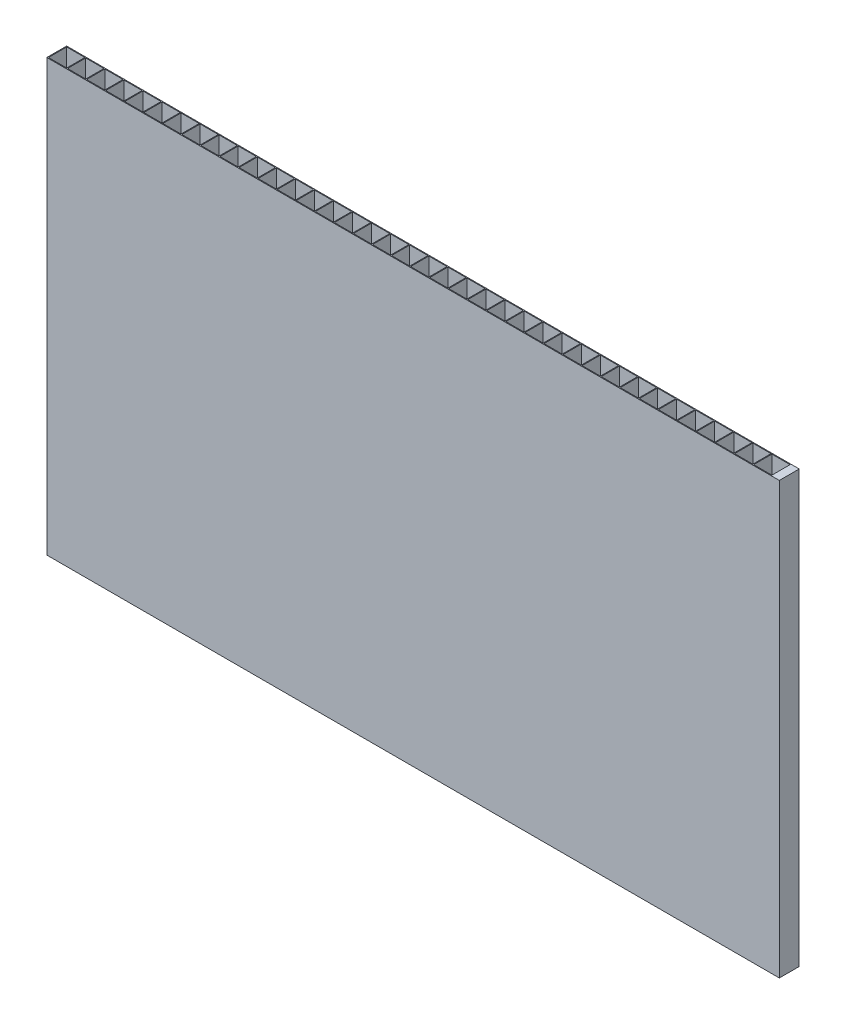
from build123d import *

# Parameters (mm, degrees)
SKETCH1_W           = 221
SKETCH1_H           = 6
SKETCH1_W_2         = 5.5
SKETCH1_H_2         = 5.5
BOSS_EXTRUDE1_DEPTH = 130


with BuildPart() as part:
    # Sketch1 → Boss-Extrude1 (new body)
    with BuildSketch(Plane(origin=(0, 0, 0), x_dir=(1, 0, 0), z_dir=(0, 1, 0))):
        with Locations((110.5, 3)):
            Rectangle(SKETCH1_W, SKETCH1_H)
        with Locations((8.75, 3)):
            Rectangle(SKETCH1_W_2, SKETCH1_H_2, mode=Mode.SUBTRACT)
        with Locations((3, 3)):
            Rectangle(SKETCH1_W_2, SKETCH1_H_2, mode=Mode.SUBTRACT)
        with Locations((14.5, 3)):
            Rectangle(SKETCH1_W_2, SKETCH1_H_2, mode=Mode.SUBTRACT)
        with Locations((20.25, 3)):
            Rectangle(SKETCH1_W_2, SKETCH1_H_2, mode=Mode.SUBTRACT)
        with Locations((26, 3)):
            Rectangle(SKETCH1_W_2, SKETCH1_H_2, mode=Mode.SUBTRACT)
        with Locations((31.75, 3)):
            Rectangle(SKETCH1_W_2, SKETCH1_H_2, mode=Mode.SUBTRACT)
        with Locations((37.5, 3)):
            Rectangle(SKETCH1_W_2, SKETCH1_H_2, mode=Mode.SUBTRACT)
        with Locations((43.25, 3)):
            Rectangle(SKETCH1_W_2, SKETCH1_H_2, mode=Mode.SUBTRACT)
        with Locations((49, 3)):
            Rectangle(SKETCH1_W_2, SKETCH1_H_2, mode=Mode.SUBTRACT)
        with Locations((54.75, 3)):
            Rectangle(SKETCH1_W_2, SKETCH1_H_2, mode=Mode.SUBTRACT)
        with Locations((60.5, 3)):
            Rectangle(SKETCH1_W_2, SKETCH1_H_2, mode=Mode.SUBTRACT)
        with Locations((66.25, 3)):
            Rectangle(SKETCH1_W_2, SKETCH1_H_2, mode=Mode.SUBTRACT)
        with Locations((72, 3)):
            Rectangle(SKETCH1_W_2, SKETCH1_H_2, mode=Mode.SUBTRACT)
        with Locations((77.75, 3)):
            Rectangle(SKETCH1_W_2, SKETCH1_H_2, mode=Mode.SUBTRACT)
        with Locations((83.5, 3)):
            Rectangle(SKETCH1_W_2, SKETCH1_H_2, mode=Mode.SUBTRACT)
        with Locations((89.25, 3)):
            Rectangle(SKETCH1_W_2, SKETCH1_H_2, mode=Mode.SUBTRACT)
        with Locations((95, 3)):
            Rectangle(SKETCH1_W_2, SKETCH1_H_2, mode=Mode.SUBTRACT)
        with Locations((100.75, 3)):
            Rectangle(SKETCH1_W_2, SKETCH1_H_2, mode=Mode.SUBTRACT)
        with Locations((106.5, 3)):
            Rectangle(SKETCH1_W_2, SKETCH1_H_2, mode=Mode.SUBTRACT)
        with Locations((112.25, 3)):
            Rectangle(SKETCH1_W_2, SKETCH1_H_2, mode=Mode.SUBTRACT)
        with Locations((118, 3)):
            Rectangle(SKETCH1_W_2, SKETCH1_H_2, mode=Mode.SUBTRACT)
        with Locations((123.75, 3)):
            Rectangle(SKETCH1_W_2, SKETCH1_H_2, mode=Mode.SUBTRACT)
        with Locations((129.5, 3)):
            Rectangle(SKETCH1_W_2, SKETCH1_H_2, mode=Mode.SUBTRACT)
        with Locations((135.25, 3)):
            Rectangle(SKETCH1_W_2, SKETCH1_H_2, mode=Mode.SUBTRACT)
        with Locations((141, 3)):
            Rectangle(SKETCH1_W_2, SKETCH1_H_2, mode=Mode.SUBTRACT)
        with Locations((146.75, 3)):
            Rectangle(SKETCH1_W_2, SKETCH1_H_2, mode=Mode.SUBTRACT)
        with Locations((152.5, 3)):
            Rectangle(SKETCH1_W_2, SKETCH1_H_2, mode=Mode.SUBTRACT)
        with Locations((158.25, 3)):
            Rectangle(SKETCH1_W_2, SKETCH1_H_2, mode=Mode.SUBTRACT)
        with Locations((164, 3)):
            Rectangle(SKETCH1_W_2, SKETCH1_H_2, mode=Mode.SUBTRACT)
        with Locations((169.75, 3)):
            Rectangle(SKETCH1_W_2, SKETCH1_H_2, mode=Mode.SUBTRACT)
        with Locations((175.5, 3)):
            Rectangle(SKETCH1_W_2, SKETCH1_H_2, mode=Mode.SUBTRACT)
        with Locations((181.25, 3)):
            Rectangle(SKETCH1_W_2, SKETCH1_H_2, mode=Mode.SUBTRACT)
        with Locations((187, 3)):
            Rectangle(SKETCH1_W_2, SKETCH1_H_2, mode=Mode.SUBTRACT)
        with Locations((192.75, 3)):
            Rectangle(SKETCH1_W_2, SKETCH1_H_2, mode=Mode.SUBTRACT)
        with Locations((198.5, 3)):
            Rectangle(SKETCH1_W_2, SKETCH1_H_2, mode=Mode.SUBTRACT)
        with Locations((204.25, 3)):
            Rectangle(SKETCH1_W_2, SKETCH1_H_2, mode=Mode.SUBTRACT)
        with Locations((210, 3)):
            Rectangle(SKETCH1_W_2, SKETCH1_H_2, mode=Mode.SUBTRACT)
        with Locations((215.75, 3)):
            Rectangle(SKETCH1_W_2, SKETCH1_H_2, mode=Mode.SUBTRACT)
    extrude(amount=BOSS_EXTRUDE1_DEPTH)


solid = part.part
